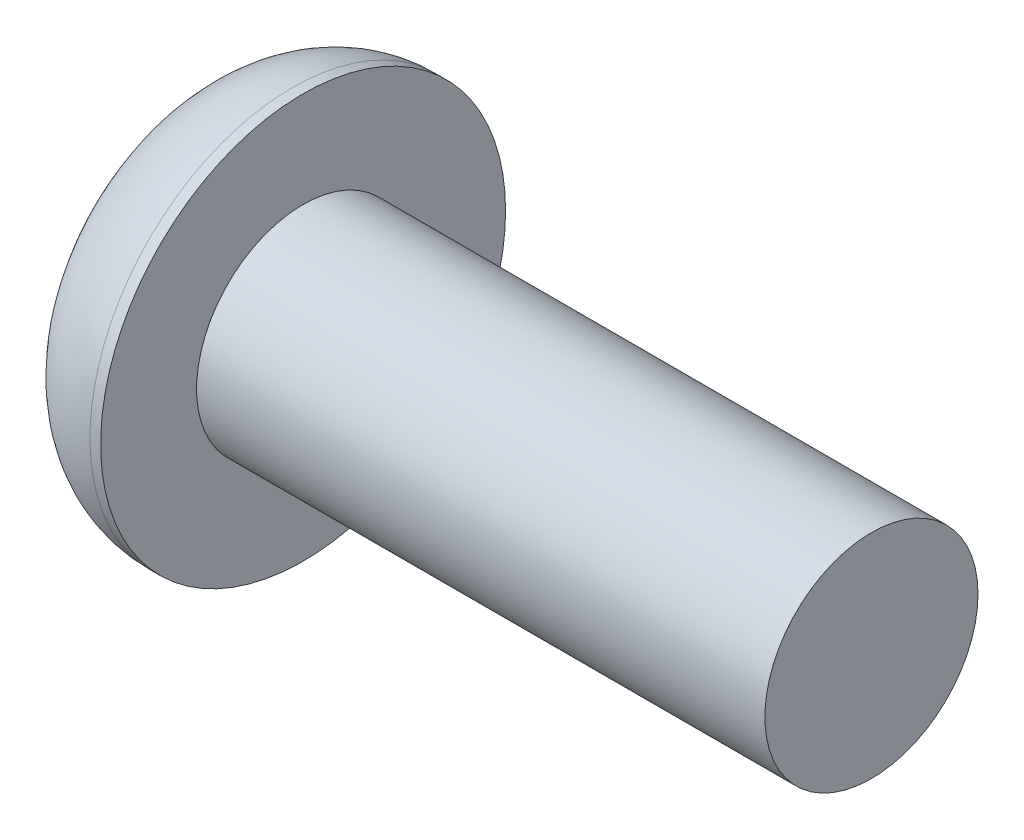
from build123d import *

# Parameters (mm, degrees)
CUT_EXTRUDE1_DEPTH = 1.04


with BuildPart() as part:
    # Sketch1 → Revolve1 (revolve)
    with BuildSketch(Plane(origin=(0, 0, 0), x_dir=(1, 0, 0), z_dir=(0, 1, 0))):
        with BuildLine():
            Line((0, 0), (9.65, 0))
            Line((9.65, 0), (9.65, 1.5))
            Line((9.65, 1.5), (1.65, 1.5))
            Line((1.65, 1.5), (1.65, 2.85))
            Line((1.65, 2.85), (1.5, 2.85))
            ThreePointArc((1.5, 2.85), (0.439339828, 2.410660172), (0, 1.35))
            Line((0, 1.35), (0, 0))
        make_face()
    revolve(axis=Axis((0, 0, 0), (-1, 0, 0)))

    # Sketch2 → Cut-Extrude1 (cut)
    with BuildSketch(Plane.ZY):
        Polygon((1.154700538, 0), (0.577350269, 1), (-0.577350269, 1), (-1.154700538, 0), (-0.577350269, -1), (0.577350269, -1), align=None)
    extrude(amount=-CUT_EXTRUDE1_DEPTH, mode=Mode.SUBTRACT)


solid = part.part
